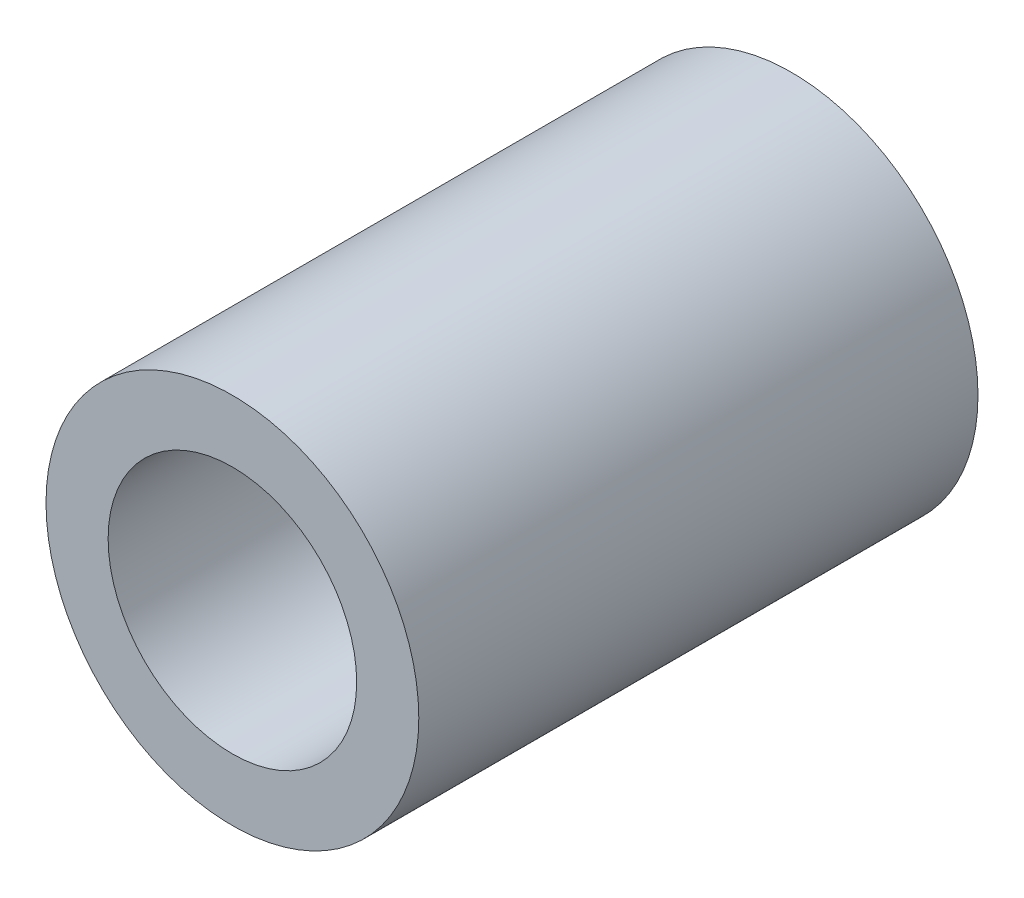
from build123d import *

# Parameters (mm, degrees)
SKETCH1_R           = 3
SKETCH1_R_2         = 2
BOSS_EXTRUDE1_DEPTH = 9


with BuildPart() as part:
    # Sketch1 → Boss-Extrude1 (new body)
    with BuildSketch(Plane.XY):
        Circle(SKETCH1_R)
        Circle(SKETCH1_R_2, mode=Mode.SUBTRACT)
    extrude(amount=BOSS_EXTRUDE1_DEPTH)


solid = part.part
